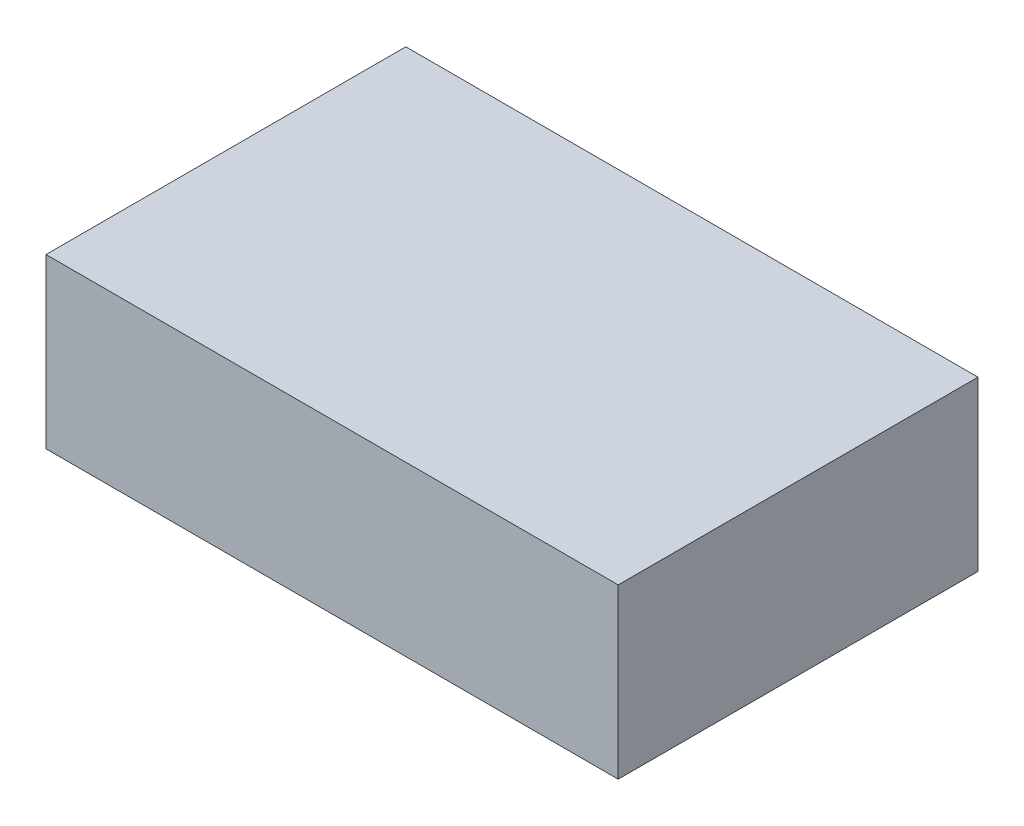
from build123d import *

# Parameters (mm, degrees)
SKETCH_1_W      = 98.6
SKETCH_1_H      = 62
EXTRUDE_1_DEPTH = 29


with BuildPart() as part:
    # 草图1 → 凸台-拉伸1 (new body)
    with BuildSketch(Plane(origin=(0, 0, 0), x_dir=(1, 0, 0), z_dir=(0, 1, 0))):
        with Locations((49.3, -31)):
            Rectangle(SKETCH_1_W, SKETCH_1_H)
    extrude(amount=EXTRUDE_1_DEPTH)


solid = part.part
